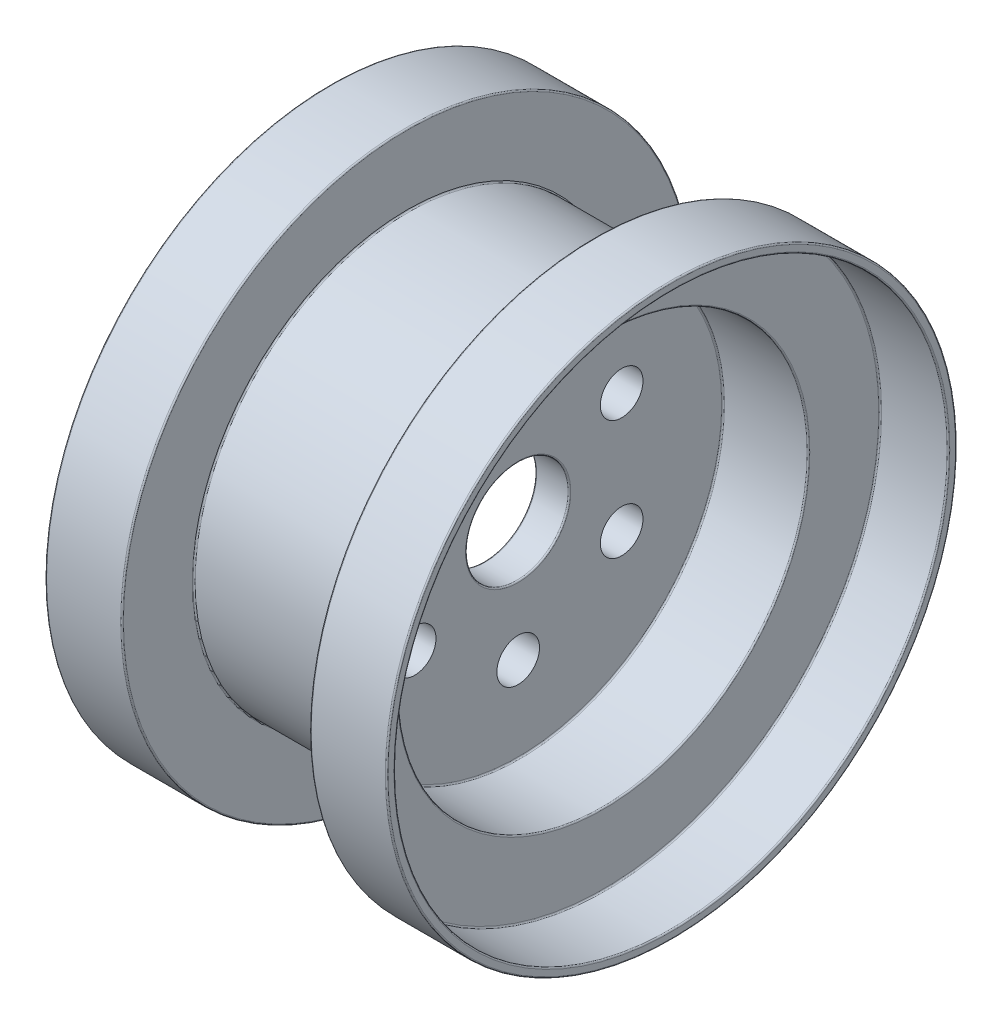
from build123d import *

# Parameters (mm, degrees)
SKETCH2_R          = 12.5
CUT_EXTRUDE1_DEPTH = 111


with BuildPart() as part:
    # Sketch1 → Revolve1 (revolve)
    with BuildSketch(Plane.XY):
        with BuildLine():
            Line((-9.2, 30), (9.2, 30))
            ThreePointArc((9.2, 30), (9.765685425, 30.234314575), (10, 30.8))
            Line((10, 30.8), (10, 119.2))
            ThreePointArc((10, 119.2), (10.234314575, 119.765685425), (10.8, 120))
            Line((10.8, 120), (59.2, 120))
            ThreePointArc((59.2, 120), (59.765685425, 120.234314575), (60, 120.8))
            Line((60, 120.8), (60, 161.2))
            ThreePointArc((60, 161.2), (60.234314575, 161.765685425), (60.8, 162))
            Line((60.8, 162), (99.2, 162))
            ThreePointArc((99.2, 162), (99.765685425, 162.234314575), (100, 162.8))
            Line((100, 162.8), (100, 166.2))
            ThreePointArc((100, 166.2), (99.765685425, 166.765685425), (99.2, 167))
            Line((99.2, 167), (55.8, 167))
            ThreePointArc((55.8, 167), (55.234314575, 166.765685425), (55, 166.2))
            Line((55, 166.2), (55, 125.8))
            ThreePointArc((55, 125.8), (54.765685425, 125.234314575), (54.2, 125))
            Line((54.2, 125), (-54.2, 125))
            ThreePointArc((-54.2, 125), (-54.765685425, 125.234314575), (-55, 125.8))
            Line((-55, 125.8), (-55, 166.2))
            ThreePointArc((-55, 166.2), (-55.234314575, 166.765685425), (-55.8, 167))
            Line((-55.8, 167), (-99.2, 167))
            ThreePointArc((-99.2, 167), (-99.765685425, 166.765685425), (-100, 166.2))
            Line((-100, 166.2), (-100, 162.8))
            ThreePointArc((-100, 162.8), (-99.765685425, 162.234314575), (-99.2, 162))
            Line((-99.2, 162), (-60.8, 162))
            ThreePointArc((-60.8, 162), (-60.234314575, 161.765685425), (-60, 161.2))
            Line((-60, 161.2), (-60, 120.8))
            ThreePointArc((-60, 120.8), (-59.765685425, 120.234314575), (-59.2, 120))
            Line((-59.2, 120), (-10.8, 120))
            ThreePointArc((-10.8, 120), (-10.234314575, 119.765685425), (-10, 119.2))
            Line((-10, 119.2), (-10, 30.8))
            ThreePointArc((-10, 30.8), (-9.765685425, 30.234314575), (-9.2, 30))
        make_face()
    revolve(axis=Axis((-81.923076923, 0, 0), (1, 0, 0)))

    # Sketch2 → Cut-Extrude1 (cut, through all)
    with BuildSketch(Plane.ZY.offset(10)):
        with Locations((0, 70)):
            Circle(SKETCH2_R)
        with Locations((60.621778265, 35)):
            Circle(SKETCH2_R)
        with Locations((60.621778265, -35)):
            Circle(SKETCH2_R)
        with Locations((0, -70)):
            Circle(SKETCH2_R)
        with Locations((-60.621778265, -35)):
            Circle(SKETCH2_R)
        with Locations((-60.621778265, 35)):
            Circle(SKETCH2_R)
    extrude(amount=-CUT_EXTRUDE1_DEPTH, mode=Mode.SUBTRACT)


solid = part.part
